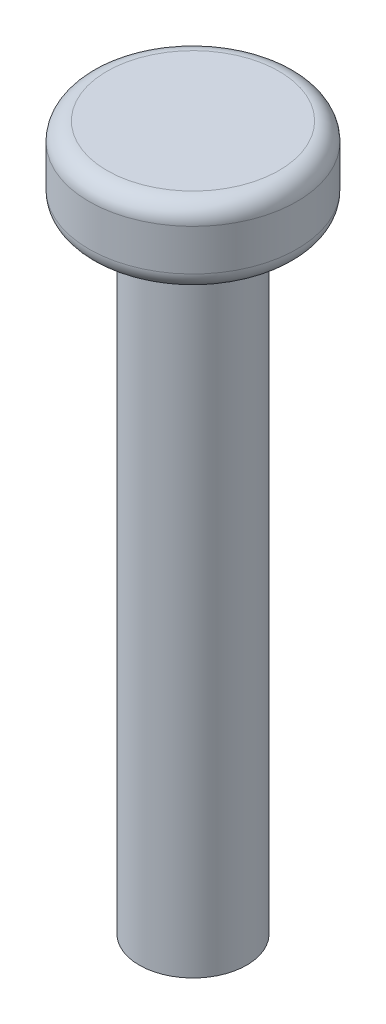
from build123d import *

# Parameters (mm, degrees)
SKETCH1_R           = 3
BOSS_EXTRUDE1_DEPTH = 35
SKETCH2_R           = 5.8
BOSS_EXTRUDE2_DEPTH = 4.3
FILLET1_R           = 1


with BuildPart() as part:
    # Sketch1 → Boss-Extrude1 (new body)
    with BuildSketch(Plane(origin=(0, 0, 0), x_dir=(1, 0, 0), z_dir=(0, 1, 0))):
        with Locations(Location((0, 0, 0), (0, 0, 270))):  # turned: the seam where the file's is
            Circle(SKETCH1_R)
    extrude(amount=BOSS_EXTRUDE1_DEPTH)

    # Sketch2 → Boss-Extrude2 (add)
    with BuildSketch(Plane(origin=(0, 35, 0), x_dir=(1, 0, 0), z_dir=(0, 1, 0))):
        with Locations(Location((0, 0, 0), (0, 0, 270))):  # turned: the seam where the file's is
            Circle(SKETCH2_R)
    extrude(amount=BOSS_EXTRUDE2_DEPTH)

    # Fillet1
    fillet1_edges = [part.edges().sort_by_distance(p)[0] for p in [
        (0, 35, -5.8),
        (0, 39.3, -5.8),
    ]]
    fillet(fillet1_edges, radius=FILLET1_R)


solid = part.part
